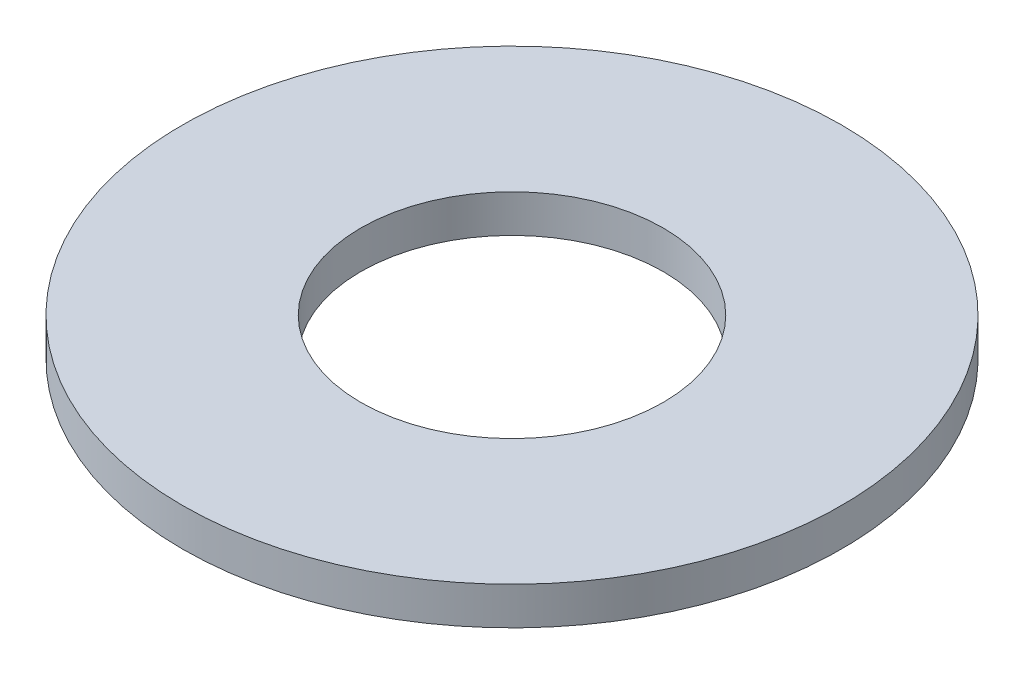
from build123d import *

# Parameters (mm, degrees)
SKETCH1_R           = 9.525
BOSS_EXTRUDE1_DEPTH = 1.0922
SKETCH5_R           = 4.3688
CUT_EXTRUDE1_DEPTH  = 14.514590295


with BuildPart() as part:
    # Sketch1 → Boss-Extrude1 (new body)
    with BuildSketch(Plane(origin=(0, 0, 0), x_dir=(1, 0, 0), z_dir=(0, 1, 0))):
        Circle(SKETCH1_R)
    extrude(amount=BOSS_EXTRUDE1_DEPTH)

    # Sketch5 → Cut-Extrude1 (cut, through all)
    with BuildSketch(Plane(origin=(0, 1.0922, 0), x_dir=(-1, 0, 0), z_dir=(0, 1, 0))):
        Circle(SKETCH5_R)
    extrude(amount=-CUT_EXTRUDE1_DEPTH, mode=Mode.SUBTRACT)


solid = part.part
